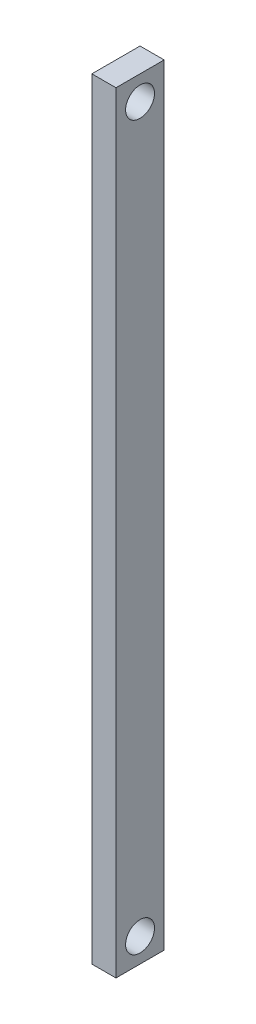
from build123d import *

# Parameters (mm, degrees)
SKETCH1_W           = 10
SKETCH1_H           = 160
BOSS_EXTRUDE1_DEPTH = 5
SKETCH3_R           = 3
CUT_EXTRUDE2_DEPTH  = 5


with BuildPart() as part:
    # Sketch1 → Boss-Extrude1 (new body)
    with BuildSketch(Plane(origin=(0, 0, 0), x_dir=(0, 0, -1), z_dir=(1, 0, 0))):
        Rectangle(SKETCH1_W, SKETCH1_H)
    extrude(amount=BOSS_EXTRUDE1_DEPTH)

    # Sketch3 → Cut-Extrude2 (cut)
    with BuildSketch(Plane(origin=(5, 0, 0), x_dir=(0, 0, -1), z_dir=(1, 0, 0))):
        with Locations((0, 75)):
            Circle(SKETCH3_R)
        with Locations((0, -75)):
            Circle(SKETCH3_R)
    extrude(amount=-CUT_EXTRUDE2_DEPTH, mode=Mode.SUBTRACT)


solid = part.part
